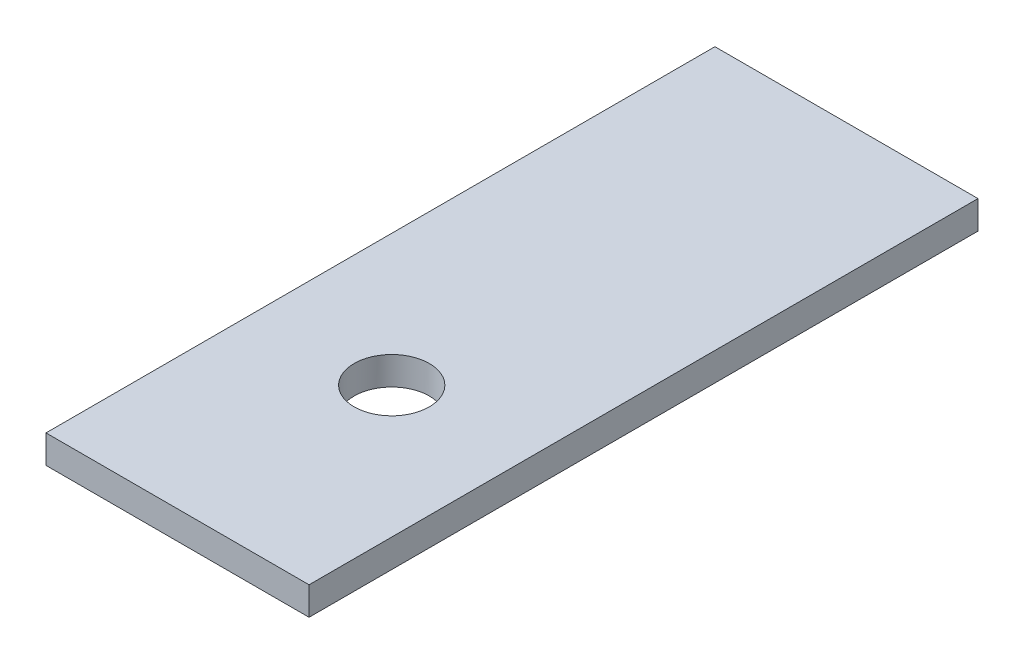
from build123d import *

# Parameters (mm, degrees)
SKETCH1_W           = 28
SKETCH1_H           = 71.2
BOSS_EXTRUDE1_DEPTH = 3
SKETCH4_R           = 1
CUT_EXTRUDE2_DEPTH  = 10
SKETCH5_R           = 4
CUT_EXTRUDE3_DEPTH  = 10
SKETCH10_R          = 1.75
CUT_EXTRUDE9_DEPTH  = 1.6
SKETCH12_R          = 1.75
BOSS_EXTRUDE2_DEPTH = 3


with BuildPart() as part:
    # Sketch1 → Boss-Extrude1 (new body)
    with BuildSketch(Plane(origin=(0, 0, 0), x_dir=(1, 0, 0), z_dir=(0, 1, 0))):
        Rectangle(SKETCH1_W, SKETCH1_H)
    extrude(amount=BOSS_EXTRUDE1_DEPTH)

    # Sketch4 → Cut-Extrude2 (cut)
    with BuildSketch(Plane(origin=(0, 3, 0), x_dir=(1, 0, 0), z_dir=(0, 1, 0))):
        with Locations((7, -12.8)):
            Circle(SKETCH4_R)
        with Locations((0, -19.8)):
            Circle(SKETCH4_R)
        with Locations((-7, -12.8)):
            Circle(SKETCH4_R)
        with Locations((0, -5.8)):
            Circle(SKETCH4_R)
    extrude(amount=-CUT_EXTRUDE2_DEPTH, mode=Mode.SUBTRACT)

    # Sketch5 → Cut-Extrude3 (cut)
    with BuildSketch(Plane(origin=(0, 3, 0), x_dir=(1, 0, 0), z_dir=(0, 1, 0))):
        with Locations((0, -12.8)):
            Circle(SKETCH5_R)
    extrude(amount=-CUT_EXTRUDE3_DEPTH, mode=Mode.SUBTRACT)

    # Sketch10 → Cut-Extrude9 (cut)
    with BuildSketch(Plane(origin=(0, 3, 0), x_dir=(1, 0, 0), z_dir=(0, 1, 0))):
        with Locations((0, -19.8)):
            Circle(SKETCH10_R)
        with Locations((-7, -12.8)):
            Circle(SKETCH10_R)
        with Locations((0, -5.8)):
            Circle(SKETCH10_R)
        with Locations((7, -12.8)):
            Circle(SKETCH10_R)
    extrude(amount=-CUT_EXTRUDE9_DEPTH, mode=Mode.SUBTRACT)

    # Sketch12 → Boss-Extrude2 (add)
    with BuildSketch(Plane(origin=(0, 3, 0), x_dir=(1, 0, 0), z_dir=(0, 1, 0))):
        with Locations((0, -19.8)):
            Circle(SKETCH12_R)
        with Locations((-7, -12.8)):
            Circle(SKETCH12_R)
        with Locations((0, -5.8)):
            Circle(SKETCH12_R)
        with Locations((7, -12.8)):
            Circle(SKETCH12_R)
    extrude(amount=-BOSS_EXTRUDE2_DEPTH)


solid = part.part
